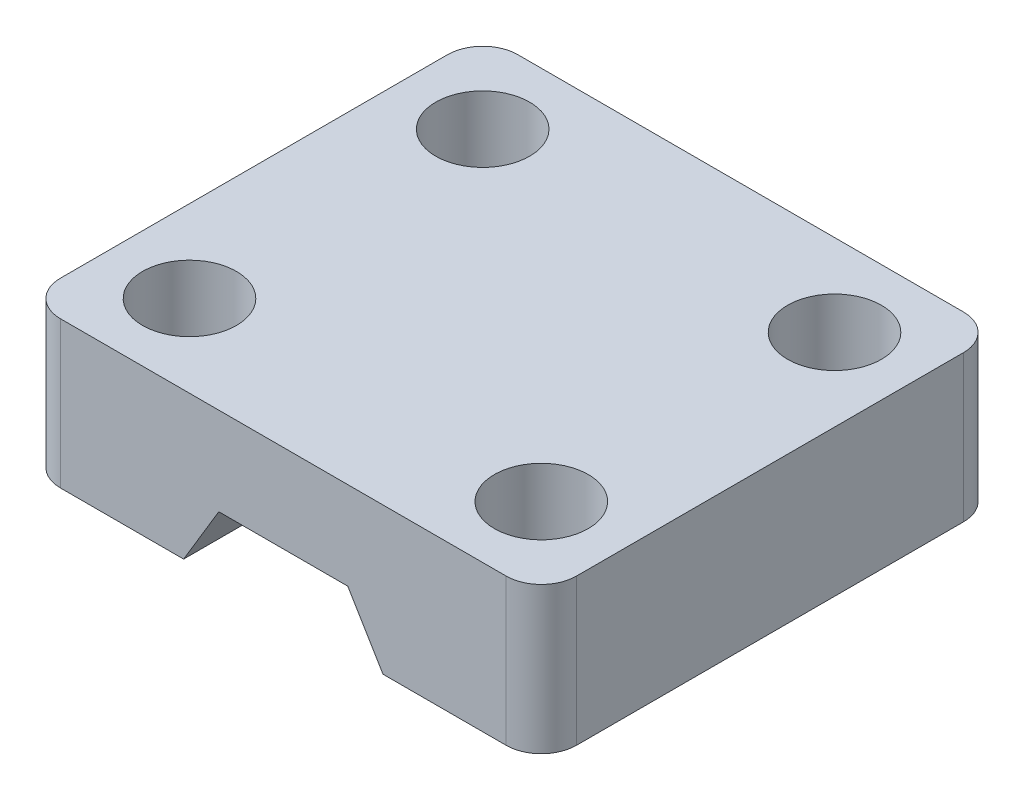
from build123d import *

# Parameters (mm, degrees)
BOSS_EXTRUDE1_DEPTH = 39
SKETCH2_R           = 4
CUT_EXTRUDE1_DEPTH  = 13.5
FILLET1_R           = 3


with BuildPart() as part:
    # Sketch1 → Boss-Extrude1 (new body)
    with BuildSketch(Plane.XY):
        Polygon((13.5, -12.5), (16.5, -7.5), (27.5, -7.5), (30.5, -12.5), (44, -12.5), (44, 0), (0, 0), (0, -12.5), align=None)
    extrude(amount=BOSS_EXTRUDE1_DEPTH)

    # Sketch2 → Cut-Extrude1 (cut, through all)
    with BuildSketch(Plane(origin=(0, 0, 0), x_dir=(1, 0, 0), z_dir=(0, 1, 0))):
        with Locations((7, -7)):
            Circle(SKETCH2_R)
        with Locations((37, -7)):
            Circle(SKETCH2_R)
        with Locations((37, -32)):
            Circle(SKETCH2_R)
        with Locations((7, -32)):
            Circle(SKETCH2_R)
    extrude(amount=-CUT_EXTRUDE1_DEPTH, mode=Mode.SUBTRACT)

    # Fillet1
    fillet1_edges = [part.edges().sort_by_distance(p)[0] for p in [
        (0, -6.25, 0),
        (44, -6.25, 39),
        (0, -6.25, 39),
        (44, -6.25, 0),
    ]]
    fillet(fillet1_edges, radius=FILLET1_R)


solid = part.part
